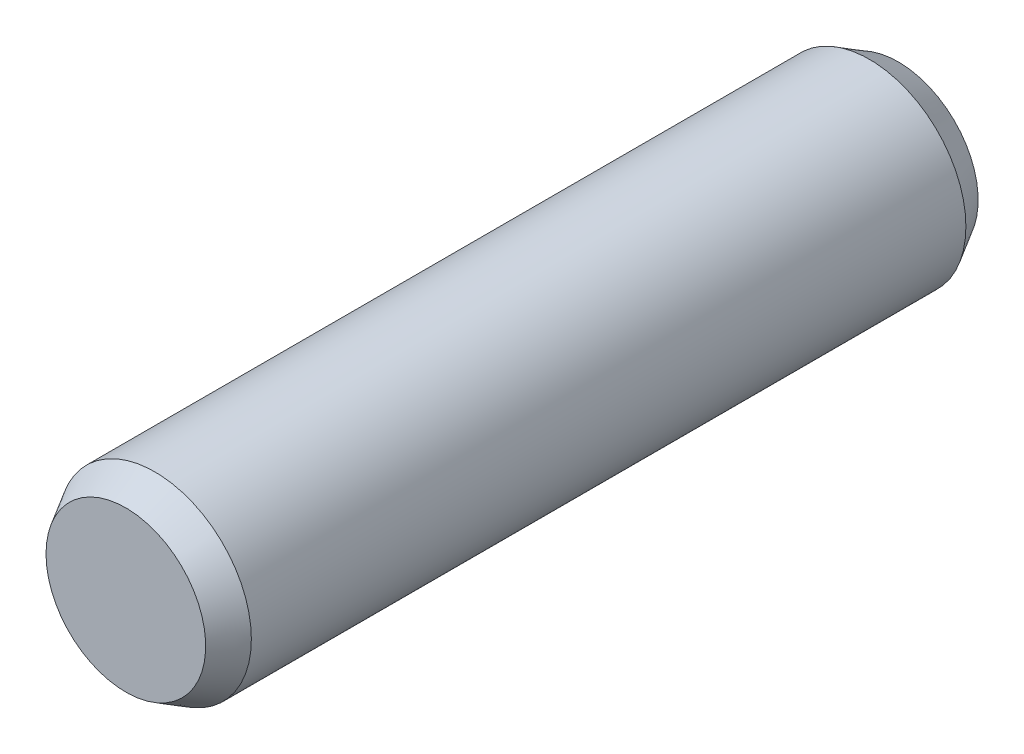
from build123d import *


with BuildPart() as part:
    # Skizze1 → Rotation1 (revolve)
    with BuildSketch(Plane(origin=(0, 0, 0), x_dir=(0, 0, -1), z_dir=(1, 0, 0))):
        Polygon((-37, 10), (37, 10), (40, 8.267949192), (40, 0), (-40, 0), (-40, 8.267949192), align=None)
    revolve(axis=Axis((0, 0, -40), (0, 0, 1)))


solid = part.part
